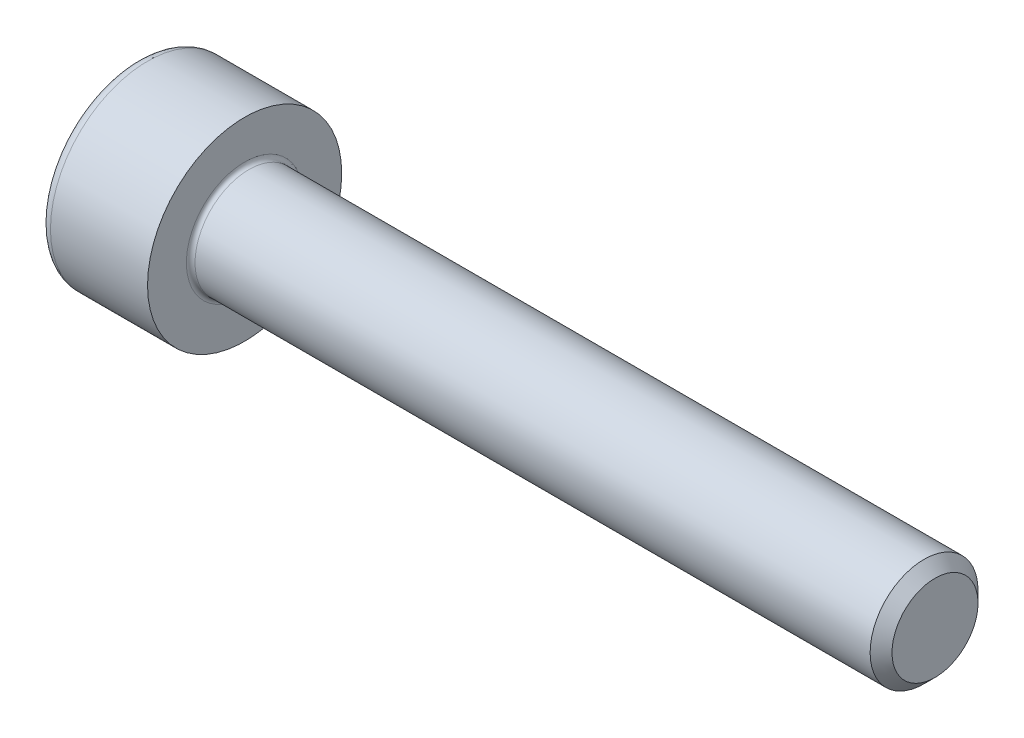
from build123d import *

# Parameters (mm, degrees)
FILLET1_R   = 0.1
FILLET2_R   = 0.25
HEX_2_DEPTH = 1.1


with BuildPart() as part:
    # BodySke → Base-Revolve (revolve)
    with BuildSketch(Plane.XY):
        Polygon((0, 0), (0, 2.25), (2.5, 2.25), (2.5, 1.25), (18.2465, 1.25), (18.5, 0.9965), (18.5, 0), align=None)
    revolve(axis=Axis((-31.75, 0, 0), (1, 0, 0)))

    # Fillet1
    fillet1_edges = [part.edges().sort_by_distance(p)[0] for p in [
        (2.5, -1.25, 0),
    ]]
    fillet(fillet1_edges, radius=FILLET1_R)

    # Fillet2
    fillet2_edges = [part.edges().sort_by_distance(p)[0] for p in [
        (0, -2.25, 0),
    ]]
    fillet(fillet2_edges, radius=FILLET2_R)

    # Sketch2 → Hex-PreBroach (revolve, cut)
    with BuildSketch(Plane.XY):
        Polygon((0, 1.01), (1.1, 1.01), (1.683123772, 0), (0, 0), align=None)
    revolve(axis=Axis((0, 0, 0), (1, 0, 0)), mode=Mode.SUBTRACT)

    # Sketch3 → Hex 2 (cut)
    with BuildSketch(Plane(origin=(0, 0, 0), x_dir=(0, 0.5, 0.866025404), z_dir=(-1, 0, 0))):
        Polygon((0.583123772, 1.01), (-0.583123772, 1.01), (-1.166247544, 0), (-0.583123772, -1.01), (0.583123772, -1.01), (1.166247544, 0), align=None)
    extrude(amount=-HEX_2_DEPTH, mode=Mode.SUBTRACT)


solid = part.part
